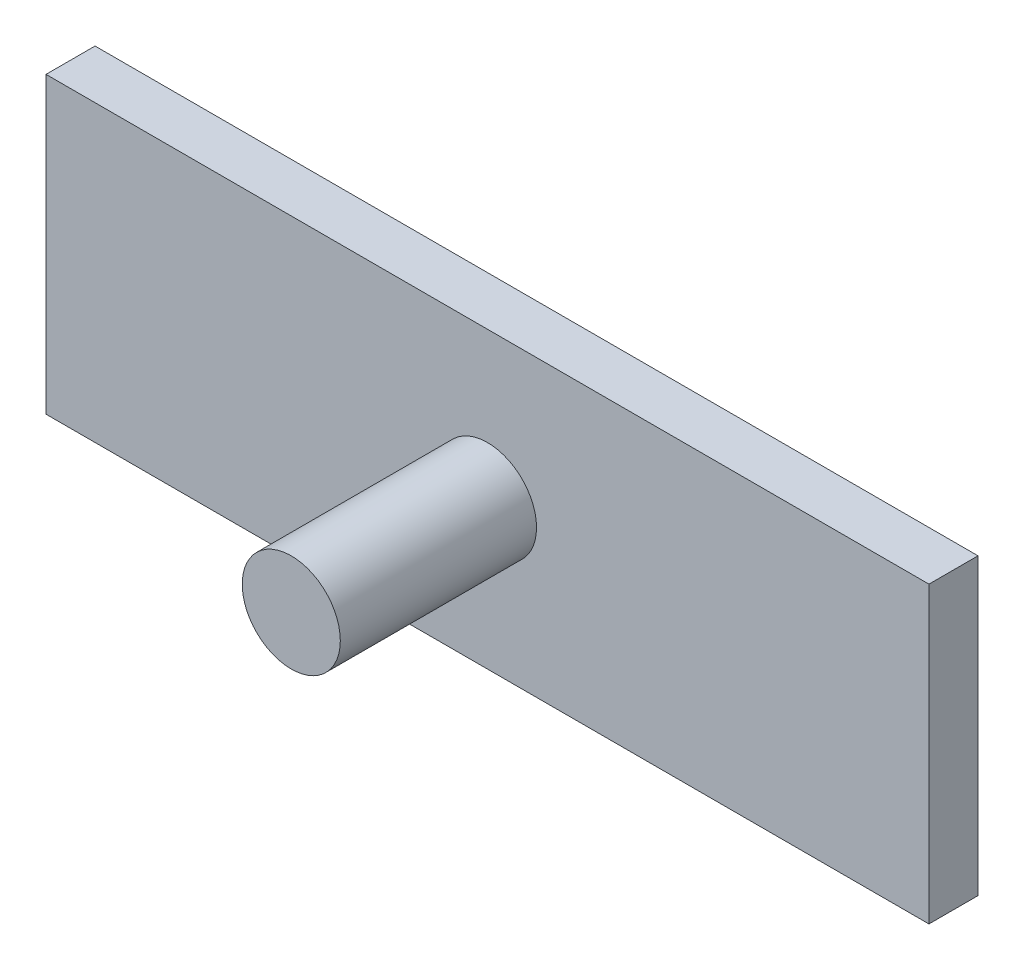
from build123d import *

# Parameters (mm, degrees)
ESQUISSE1_W        = 90
ESQUISSE1_H        = 30
BOSS_EXTRU_1_DEPTH = 5
ESQUISSE2_R        = 5
BOSS_EXTRU_2_DEPTH = 20


with BuildPart() as part:
    # Esquisse1 → Boss.-Extru.1 (new body)
    with BuildSketch(Plane.XY):
        with Locations((-45, 15)):
            Rectangle(ESQUISSE1_W, ESQUISSE1_H)
    extrude(amount=BOSS_EXTRU_1_DEPTH)

    # Esquisse2 → Boss.-Extru.2 (add)
    with BuildSketch(Plane.XY.offset(5)):
        with Locations((-45, 15)):
            Circle(ESQUISSE2_R)
    extrude(amount=BOSS_EXTRU_2_DEPTH)


solid = part.part
